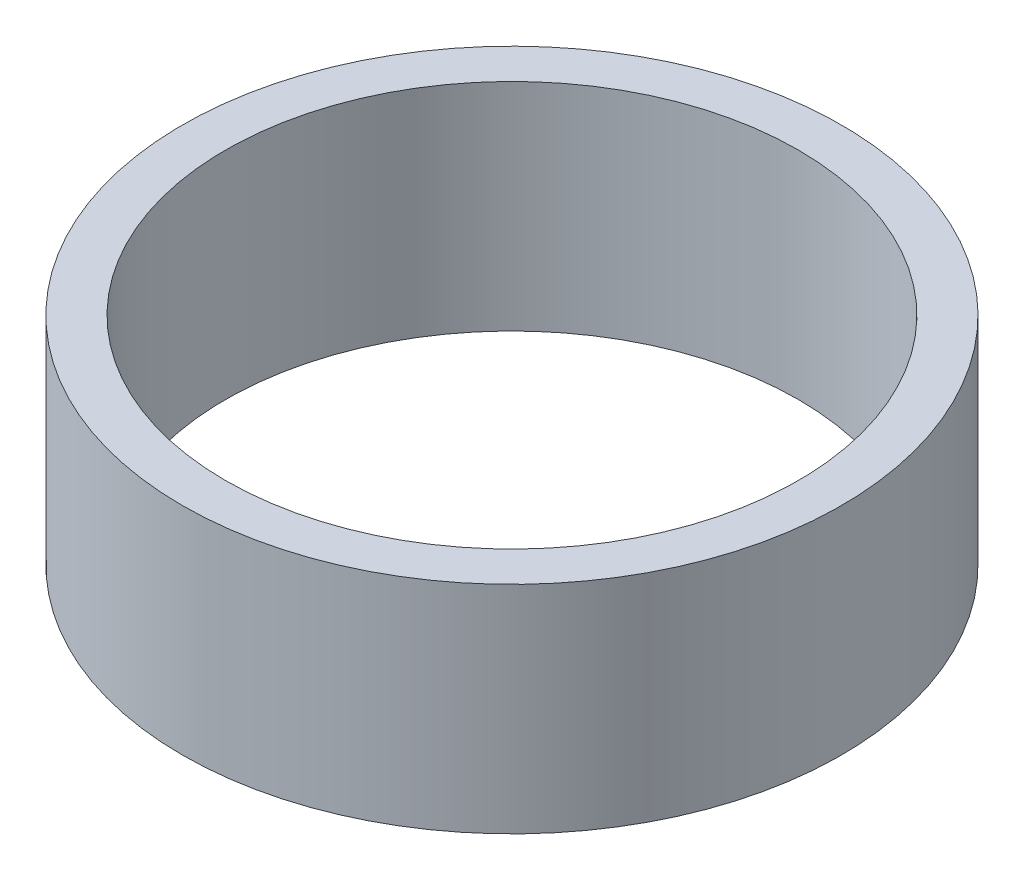
from build123d import *

# Parameters (mm, degrees)
SKETCH_2_R      = 15.25
SKETCH_2_R_2    = 13.25
EXTRUDE_1_DEPTH = 10


with BuildPart() as part:
    # ｽｹｯﾁ2 → ﾎﾞｽ - 押し出し1 (new body)
    with BuildSketch(Plane(origin=(0, 0, 0), x_dir=(1, 0, 0), z_dir=(0, 1, 0))):
        Circle(SKETCH_2_R)
        Circle(SKETCH_2_R_2, mode=Mode.SUBTRACT)
    extrude(amount=EXTRUDE_1_DEPTH)


solid = part.part
